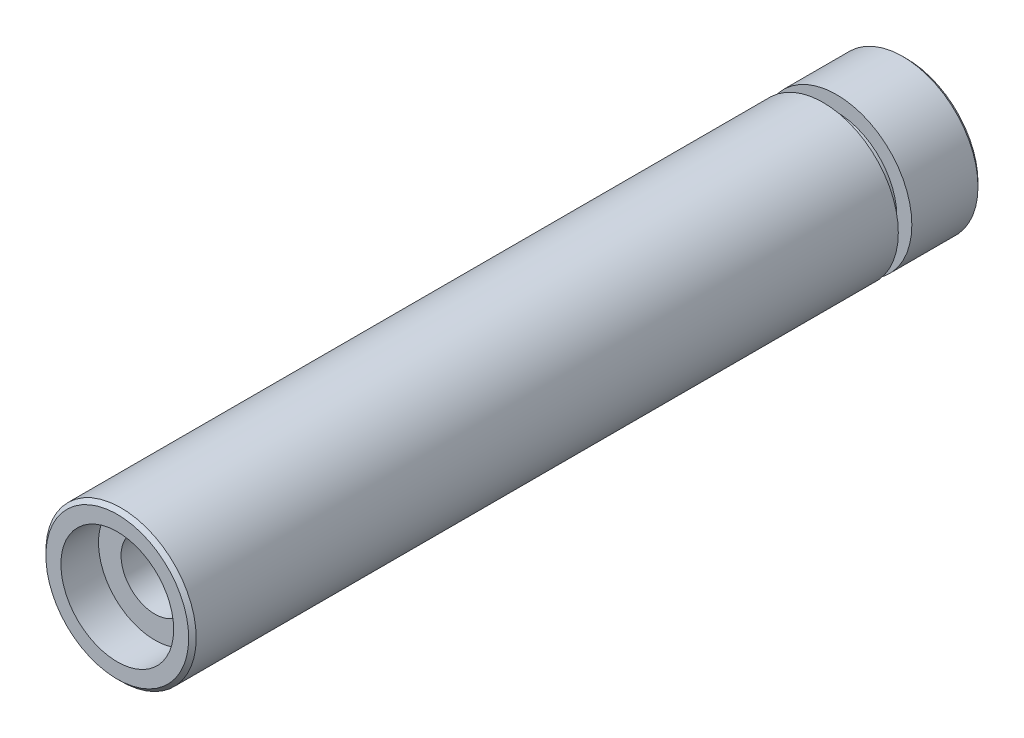
from build123d import *

# Parameters (mm, degrees)
SKETCH1_R           = 10
BOSS_EXTRUDE1_DEPTH = 9.3
SKETCH3_R           = 8
BOSS_EXTRUDE2_DEPTH = 1.8
SKETCH4_R           = 10
BOSS_EXTRUDE3_DEPTH = 93.9
SKETCH5_R           = 7.5
CUT_EXTRUDE1_DEPTH  = 5
SKETCH6_R           = 4.5
CUT_EXTRUDE2_DEPTH  = 95
SKETCH7_R           = 7.5
CUT_EXTRUDE3_DEPTH  = 5
CHAMFER1_SIZE       = 0.5


with BuildPart() as part:
    # Sketch1 → Boss-Extrude1 (new body)
    with BuildSketch(Plane.XY):
        Circle(SKETCH1_R)
    extrude(amount=BOSS_EXTRUDE1_DEPTH)

    # Sketch3 → Boss-Extrude2 (add)
    with BuildSketch(Plane.XY.offset(9.3)):
        Circle(SKETCH3_R)
    extrude(amount=BOSS_EXTRUDE2_DEPTH)

    # Sketch4 → Boss-Extrude3 (add)
    with BuildSketch(Plane.XY.offset(11.1)):
        Circle(SKETCH4_R)
    extrude(amount=BOSS_EXTRUDE3_DEPTH)

    # Sketch5 → Cut-Extrude1 (cut)
    with BuildSketch(Plane(origin=(0, 0, 0), x_dir=(-1, 0, 0), z_dir=(0, 0, -1))):
        Circle(SKETCH5_R)
    extrude(amount=-CUT_EXTRUDE1_DEPTH, mode=Mode.SUBTRACT)

    # Sketch6 → Cut-Extrude2 (cut)
    with BuildSketch(Plane(origin=(0, 0, 5), x_dir=(-1, 0, 0), z_dir=(0, 0, -1))):
        Circle(SKETCH6_R)
    extrude(amount=-CUT_EXTRUDE2_DEPTH, mode=Mode.SUBTRACT)

    # Sketch7 → Cut-Extrude3 (cut)
    with BuildSketch(Plane.XY.offset(105)):
        Circle(SKETCH7_R)
    extrude(amount=-CUT_EXTRUDE3_DEPTH, mode=Mode.SUBTRACT)

    # Chamfer1
    chamfer1_edges = [part.edges().sort_by_distance(p)[0] for p in [
        (-10, 0, 0),
        (-10, 0, 105),
    ]]
    chamfer(chamfer1_edges, length=CHAMFER1_SIZE)


solid = part.part
